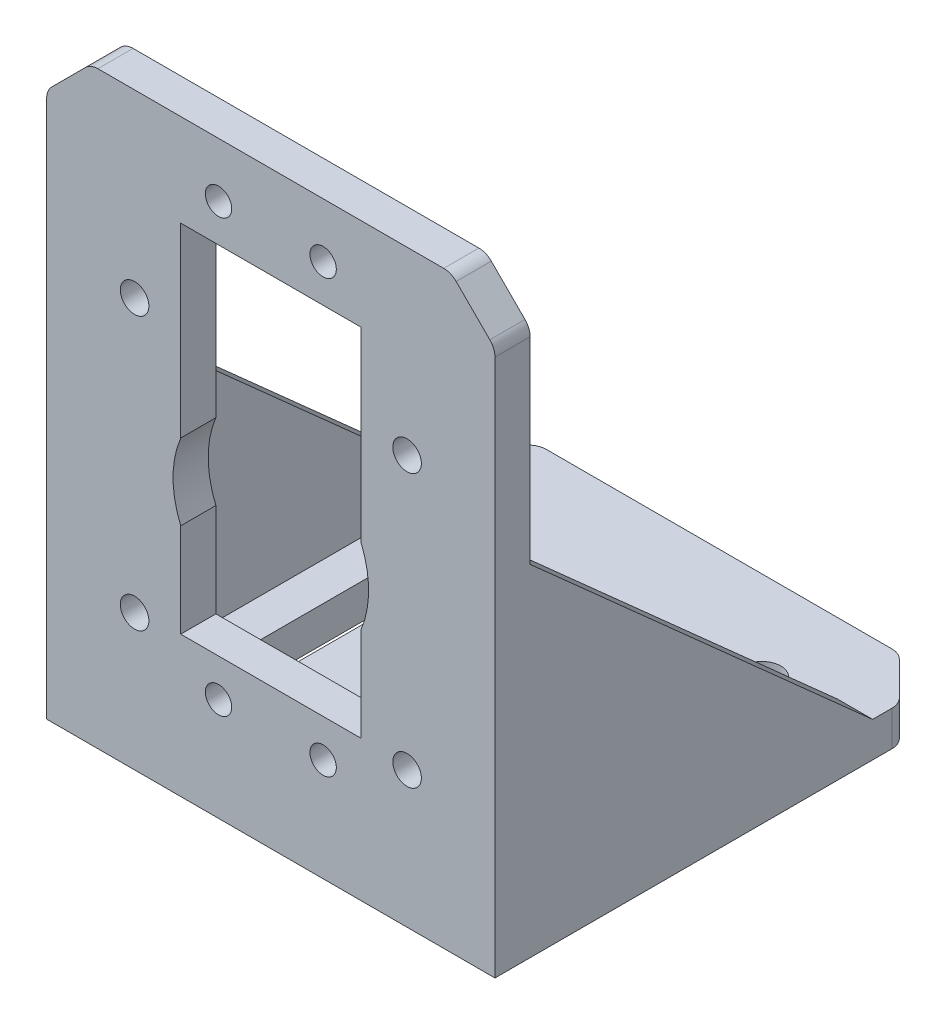
from build123d import *

# Parameters (mm, degrees)
BOSS_EXTRUDE1_DEPTH = 51
CUT_EXTRUDE2_DEPTH  = 51
SKETCH4_R           = 1.625
CUT_EXTRUDE3_DEPTH  = 51
CHAMFER1_SIZE       = 5
FILLET1_R           = 2
SKETCH5_W           = 20.5
SKETCH5_H           = 40.5
CUT_EXTRUDE4_DEPTH  = 10
RIB1_REACH          = 100.443
SKETCH6_WALL_W      = 251.096798658
SKETCH6_WALL_H      = 4
SKETCH7_R           = 1.5
CUT_EXTRUDE5_DEPTH  = 10
SKETCH2_R           = 11.125
CUT_EXTRUDE6_DEPTH  = 10


with BuildPart() as part:
    # Sketch1 → Boss-Extrude1 (new body)
    with BuildSketch(Plane(origin=(0, 0, 0), x_dir=(0, 0, -1), z_dir=(1, 0, 0))):
        Polygon((0, 0), (0, 67), (4, 67), (4, 4), (51, 4), (51, 0), align=None)
    extrude(amount=BOSS_EXTRUDE1_DEPTH)

    # Sketch3 → Cut-Extrude2 (cut)
    with BuildSketch(Plane(origin=(0, 4, 0), x_dir=(1, 0, 0), z_dir=(0, 1, 0))):
        with BuildLine():
            Line((8.34, 40.85), (8.34, 11.15))
            ThreePointArc((8.34, 11.15), (10.49, 9), (12.64, 11.15))
            Line((12.64, 11.15), (12.64, 40.85))
            ThreePointArc((12.64, 40.85), (10.49, 43), (8.34, 40.85))
        make_face()
        with BuildLine():
            Line((38.36, 40.85), (38.36, 11.15))
            ThreePointArc((38.36, 11.15), (40.51, 9), (42.66, 11.15))
            Line((42.66, 11.15), (42.66, 40.85))
            ThreePointArc((42.66, 40.85), (40.51, 43), (38.36, 40.85))
        make_face()
    extrude(amount=-CUT_EXTRUDE2_DEPTH, mode=Mode.SUBTRACT)

    # Sketch4 → Cut-Extrude3 (cut)
    with BuildSketch(Plane.XY):
        with Locations((10, 46.5)):
            Circle(SKETCH4_R)
        with Locations((41, 46.5)):
            Circle(SKETCH4_R)
        with Locations((41, 15.5)):
            Circle(SKETCH4_R)
        with Locations((10, 15.5)):
            Circle(SKETCH4_R)
    extrude(amount=-CUT_EXTRUDE3_DEPTH, mode=Mode.SUBTRACT)

    # Chamfer1
    chamfer1_edges = [part.edges().sort_by_distance(p)[0] for p in [
        (51, 67, -2),
        (0, 67, -2),
        (0, 2, -51),
        (51, 2, -51),
    ]]
    chamfer(chamfer1_edges, length=CHAMFER1_SIZE)

    # Fillet1
    fillet1_edges = [part.edges().sort_by_distance(p)[0] for p in [
        (46, 2, -51),
        (5, 2, -51),
        (0, 62, -2),
        (0, 2, -46),
        (51, 62, -2),
        (51, 2, -46),
        (5, 67, -2),
        (46, 67, -2),
    ]]
    fillet(fillet1_edges, radius=FILLET1_R)

    # Sketch5 → Cut-Extrude4 (cut)
    with BuildSketch(Plane(origin=(0, 0, -4), x_dir=(-1, 0, 0), z_dir=(0, 0, -1))):
        with Locations((-25.5, 36.25)):
            Rectangle(SKETCH5_W, SKETCH5_H)
    extrude(amount=-CUT_EXTRUDE4_DEPTH, mode=Mode.SUBTRACT)

    # Sketch6 wall → Rib1 (add, up to next)
    with BuildSketch(Plane(origin=(51, 21.375514331, -23.483064602), x_dir=(0, -0.665587686923, -0.746319657397), z_dir=(0, 0.746319657397, -0.665587686923)), mode=Mode.PRIVATE) as rib1_sk1:
        with Locations((0, 2)):
            Rectangle(SKETCH6_WALL_W, SKETCH6_WALL_H)
    rib1_tool1 = extrude(rib1_sk1.sketch, amount=-RIB1_REACH, mode=Mode.PRIVATE) - part.part
    rib1 = rib1_tool1.solids().sort_by_distance((51, 21.375514331, -23.483064602))[0]
    add(rib1)

    # Mirror1: Rib1 across plane
    add(rib1.mirror(Plane.ZY.offset(-25.5)))

    # Sketch7 → Cut-Extrude5 (cut)
    with BuildSketch(Plane(origin=(0, 0, -4), x_dir=(-1, 0, 0), z_dir=(0, 0, -1))):
        with Locations(Location((-31.45, 60.8, 0), (0, 0, 90))):
            Circle(SKETCH7_R)
        with Locations(Location((-19.55, 60.8, 0), (0, 0, 90))):
            Circle(SKETCH7_R)
        with Locations(Location((-31.45, 11.7, 0), (0, 0, 90))):
            Circle(SKETCH7_R)
        with Locations(Location((-19.55, 11.7, 0), (0, 0, 90))):
            Circle(SKETCH7_R)
    extrude(amount=-CUT_EXTRUDE5_DEPTH, mode=Mode.SUBTRACT)

    # Sketch2 → Cut-Extrude6 (cut)
    with BuildSketch(Plane.XY):
        with Locations((25.5, 31)):
            Circle(SKETCH2_R)
    extrude(amount=-CUT_EXTRUDE6_DEPTH, mode=Mode.SUBTRACT)


solid = part.part
